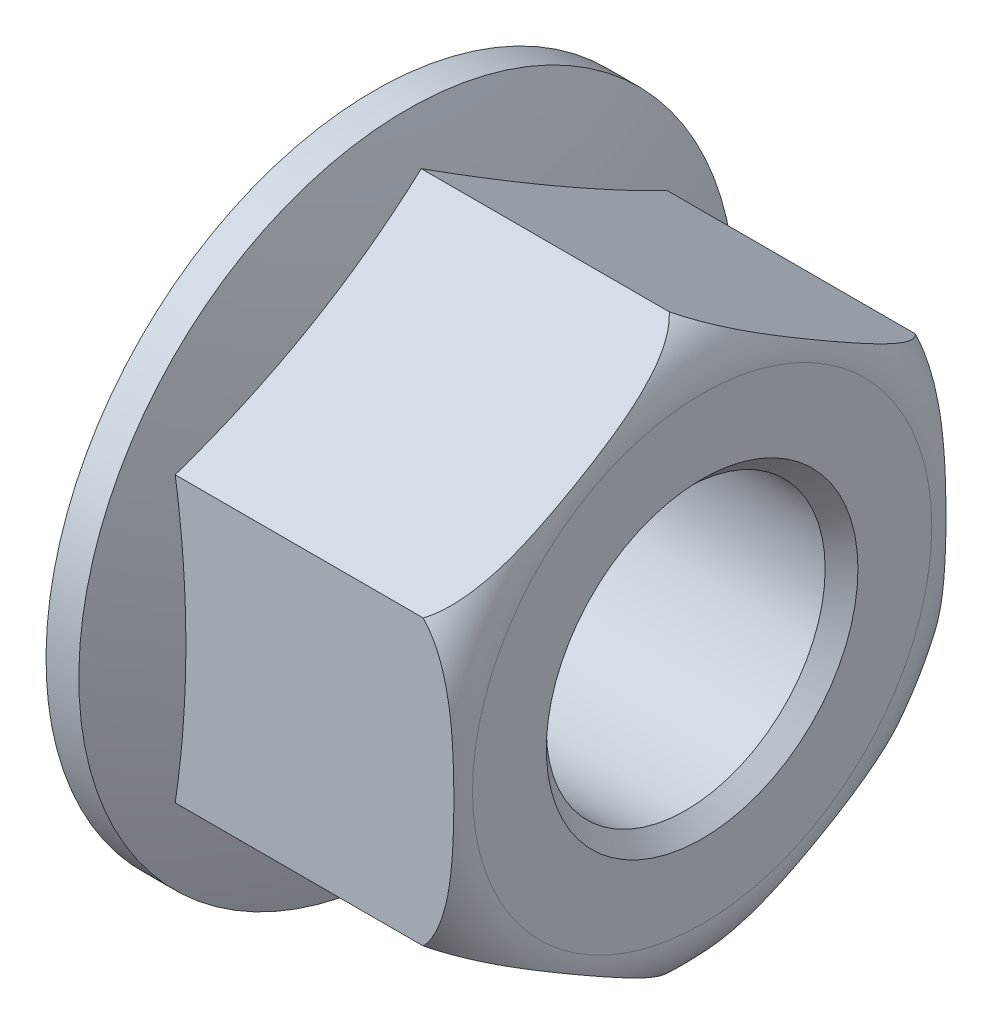
from build123d import *

# Parameters (mm, degrees)
EXTRUSION1_DEPTH        = 10
ESQUISSE4_R             = 4.25
ENL_V_MAT_EXTRU_2_DEPTH = 10
CHANFREIN1_SIZE         = 0.5


with BuildPart() as part:
    # Esquisse1 → Extrusion1 (new body)
    with BuildSketch(Plane(origin=(0, 0, 0), x_dir=(0, 0, -1), z_dir=(1, 0, 0))):
        Polygon((0, 8.660254038), (-7.5, 4.330127019), (-7.5, -4.330127019), (0, -8.660254038), (7.5, -4.330127019), (7.5, 4.330127019), align=None)
    extrude(amount=EXTRUSION1_DEPTH)

    # Esquisse2 → Enlèvement de matière-Révolution1 (revolve, cut)
    with BuildSketch(Plane.XY, mode=Mode.PRIVATE) as enl_vement_de_mati_re_r_volution1_sk:
        with BuildLine():
            Line((10, 8.660254038), (9, 8.660254038))
            ThreePointArc((9, 8.660254038), (9.730692812, 7.969077328), (10, 7))
            Line((10, 7), (10, 8.660254038))
        make_face()
    revolve(enl_vement_de_mati_re_r_volution1_sk.sketch.rotate(Axis((0, 0, 0), (1, 0, 0)), 90), axis=Axis((0, 0, 0), (1, 0, 0)), mode=Mode.SUBTRACT)  # turned: the seam where the file's is

    # Esquisse3 → Révolution1 (revolve)
    with BuildSketch(Plane.XY, mode=Mode.PRIVATE) as r_volution1_sk:
        with BuildLine():
            Line((0, 0), (0, 10))
            Line((0, 10), (1, 10))
            ThreePointArc((1, 10), (2.283685542, 5.073059362), (2.715728753, 0))
            Line((2.715728753, 0), (0, 0))
        make_face()
    revolve(r_volution1_sk.sketch.rotate(Axis((0, 0, 0), (1, 0, 0)), 180), axis=Axis((0, 0, 0), (1, 0, 0)))  # turned: the seam where the file's is

    # Esquisse4 → Enlèv. mat.-Extru.2 (cut)
    with BuildSketch(Plane(origin=(0, 0, 0), x_dir=(0, 0, -1), z_dir=(1, 0, 0))):
        Circle(ESQUISSE4_R)
    extrude(amount=ENL_V_MAT_EXTRU_2_DEPTH, mode=Mode.SUBTRACT)

    # Chanfrein1
    chanfrein1_edges = [part.edges().sort_by_distance(p)[0] for p in [
        (0, 0, 4.25),
        (10, 0, 4.25),
    ]]
    chamfer(chanfrein1_edges, length=CHANFREIN1_SIZE)


solid = part.part
